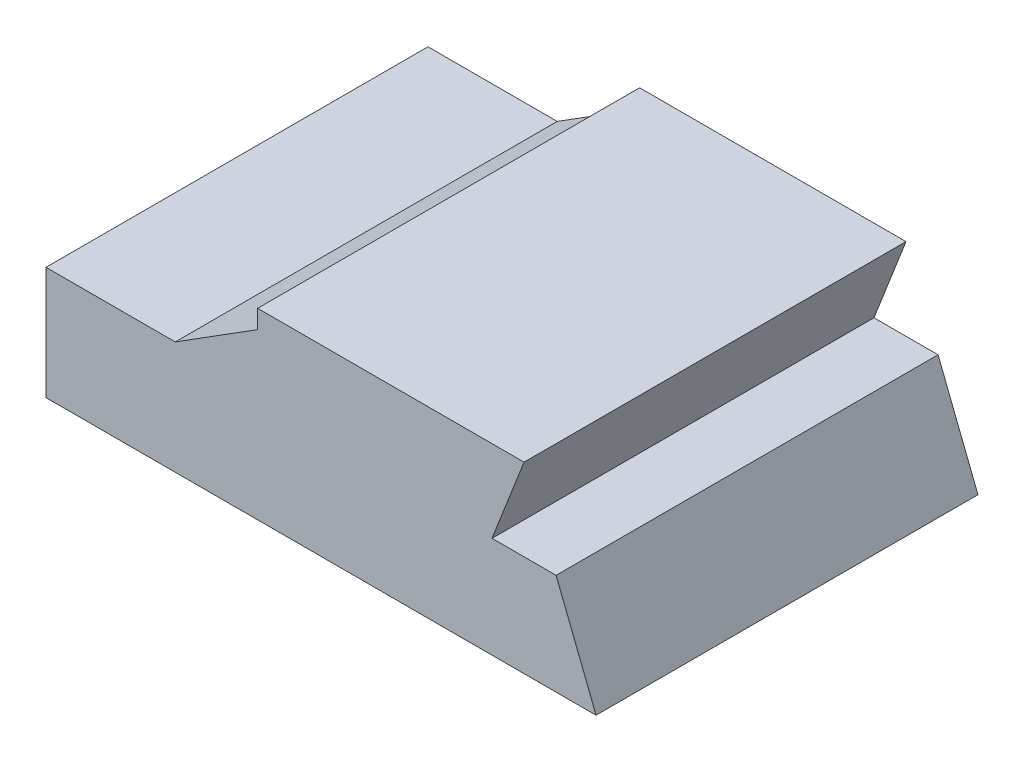
from build123d import *

# Parameters (mm, degrees)
SKETCH_1_R                     = 27.60110162
EXTRUDE_1_DEPTH                = 50
SPLIT_BODIES_1_SURFACE_1_BACK  = 231.64
SPLIT_BODIES_1_SURFACE_1_DEPTH = 463.28
SPLIT_BODIES_1_SURFACE_2_BACK  = 231.64
SPLIT_BODIES_1_SURFACE_2_DEPTH = 463.28


with BuildPart() as part:
    # 草图1 → 凸台-拉伸1 (new, symmetric)
    with BuildSketch(Plane.XY):
        with Locations((126.841, 106.3205)):
            Circle(SKETCH_1_R)
        with BuildLine():
            Line((0, 29.556947787), (33.841128496, 29.556947787))
            Line((33.841128496, 29.556947787), (55.404404979, 43.133825573))
            Line((55.404404979, 43.133825573), (55.404404979, 95.897124924))
            Line((55.404404979, 95.897124924), (92.202864513, 95.897124924))
            ThreePointArc((92.202864513, 95.897124924), (88.266951773, 109.605982584), (81.786119565, 122.311217777))
            ThreePointArc((81.786119565, 122.311217777), (81.790702408, 131.54578908), (90.169806602, 135.427533672))
            Line((90.169806602, 135.427533672), (152.632483554, 126.981321854))
            ThreePointArc((152.632483554, 126.981321854), (156.573746893, 124.561834969), (157.437634447, 120.018579331))
            Line((157.437634447, 120.018579331), (140.698476255, 47.962391292))
            Line((140.698476255, 47.962391292), (125.156200351, 47.962391292))
            Line((125.156200351, 47.962391292), (116.770080258, 26.493923855))
            Line((116.770080258, 26.493923855), (133.542320443, 26.493923855))
            Line((133.542320443, 26.493923855), (144.001, 0))
            Line((144.001, 0), (0, 0))
            Line((0, 0), (0, 29.556947787))
        make_face()
    extrude(amount=EXTRUDE_1_DEPTH, both=True)


with BuildPart() as body_2:
    # Split Bodies 1: the piece behind the surface
    add(part.part)
    # Split Bodies 1 surface: a surface, the sketch's curves swept straight by 463.28 mm
    with BuildLine(Plane.XY.offset(50).offset(-SPLIT_BODIES_1_SURFACE_1_BACK), mode=Mode.PRIVATE) as split_bodies_1_surface_1_path:
        Line((125.156200351, 47.962391292), (37.921543342, 47.962391292))
    split_bodies_1_surface_1 = Shell.extrude(split_bodies_1_surface_1_path.wire(), (0 * SPLIT_BODIES_1_SURFACE_1_DEPTH, 0 * SPLIT_BODIES_1_SURFACE_1_DEPTH, 1 * SPLIT_BODIES_1_SURFACE_1_DEPTH))
    split(bisect_by=split_bodies_1_surface_1, keep=Keep.BOTTOM)


with BuildPart() as part_1:
    add(part.part)

    # Split Bodies 1: split by a surface, the side it looks to stays
    # Split Bodies 1 surface: a surface, the sketch's curves swept straight by 463.28 mm
    with BuildLine(Plane.XY.offset(50).offset(-SPLIT_BODIES_1_SURFACE_2_BACK), mode=Mode.PRIVATE) as split_bodies_1_surface_2_path:
        Line((125.156200351, 47.962391292), (37.921543342, 47.962391292))
    split_bodies_1_surface_2 = Shell.extrude(split_bodies_1_surface_2_path.wire(), (0 * SPLIT_BODIES_1_SURFACE_2_DEPTH, 0 * SPLIT_BODIES_1_SURFACE_2_DEPTH, 1 * SPLIT_BODIES_1_SURFACE_2_DEPTH))
    split(bisect_by=split_bodies_1_surface_2, keep=Keep.TOP)


solid = part_1.part
